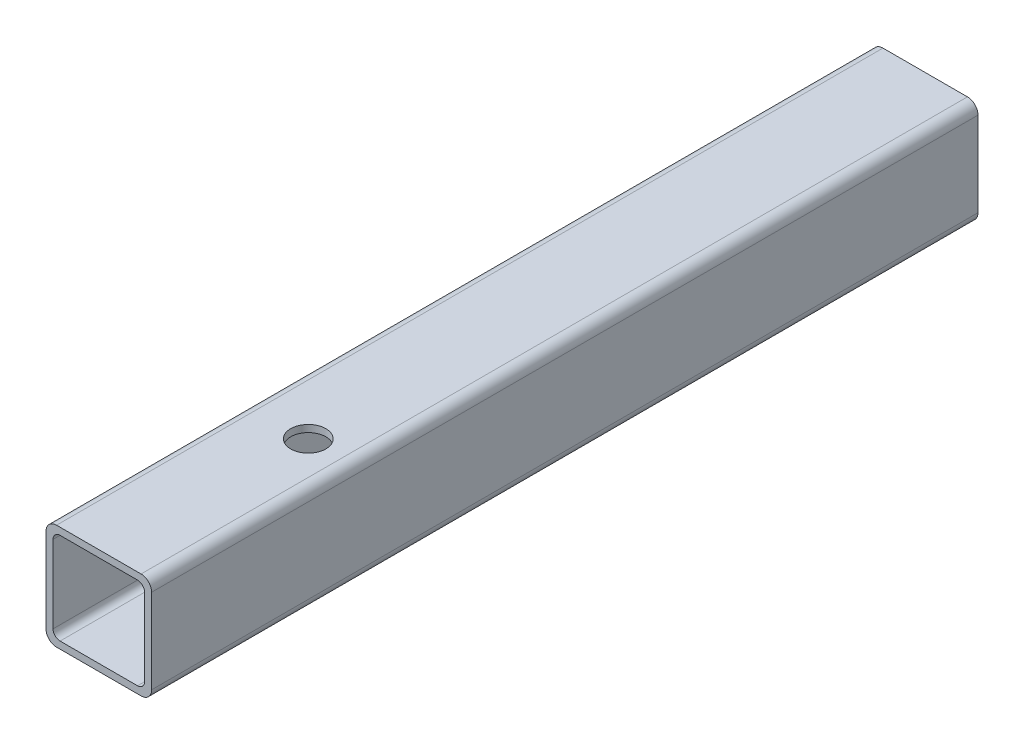
from build123d import *

# Parameters (mm, degrees)
EXTRUDE_1_DEPTH     = 234.733197
SKETCH_2_R          = 5
CUT_EXTRUDE_1_DEPTH = 31


with BuildPart() as part:
    # Эскиз1 → Бобышка-Вытянуть1 (new body)
    with BuildSketch(Plane.XY):
        with BuildLine():
            Line((-12, 0), (12, 0))
            ThreePointArc((12, 0), (14.121320344, -0.878679656), (15, -3))
            Line((15, -3), (15, -27))
            ThreePointArc((15, -27), (14.121320344, -29.121320344), (12, -30))
            Line((12, -30), (-12, -30))
            ThreePointArc((-12, -30), (-14.121320344, -29.121320344), (-15, -27))
            Line((-15, -27), (-15, -3))
            ThreePointArc((-15, -3), (-14.121320344, -0.878679656), (-12, 0))
        make_face()
        with BuildLine():
            Line((-11, -2), (11, -2))
            ThreePointArc((11, -2), (12.414213562, -2.585786438), (13, -4))
            Line((13, -4), (13, -26))
            ThreePointArc((13, -26), (12.414213562, -27.414213562), (11, -28))
            Line((11, -28), (-11, -28))
            ThreePointArc((-11, -28), (-12.414213562, -27.414213562), (-13, -26))
            Line((-13, -26), (-13, -4))
            ThreePointArc((-13, -4), (-12.414213562, -2.585786438), (-11, -2))
        make_face(mode=Mode.SUBTRACT)
    extrude(amount=-EXTRUDE_1_DEPTH)

    # Эскиз2 → Вырез-Вытянуть1 (cut, through all)
    with BuildSketch(Plane(origin=(0, 0, 0), x_dir=(1, 0, 0), z_dir=(0, 1, 0))):
        with Locations((2.5, 57)):
            Circle(SKETCH_2_R)
    extrude(amount=-CUT_EXTRUDE_1_DEPTH, mode=Mode.SUBTRACT)


solid = part.part
